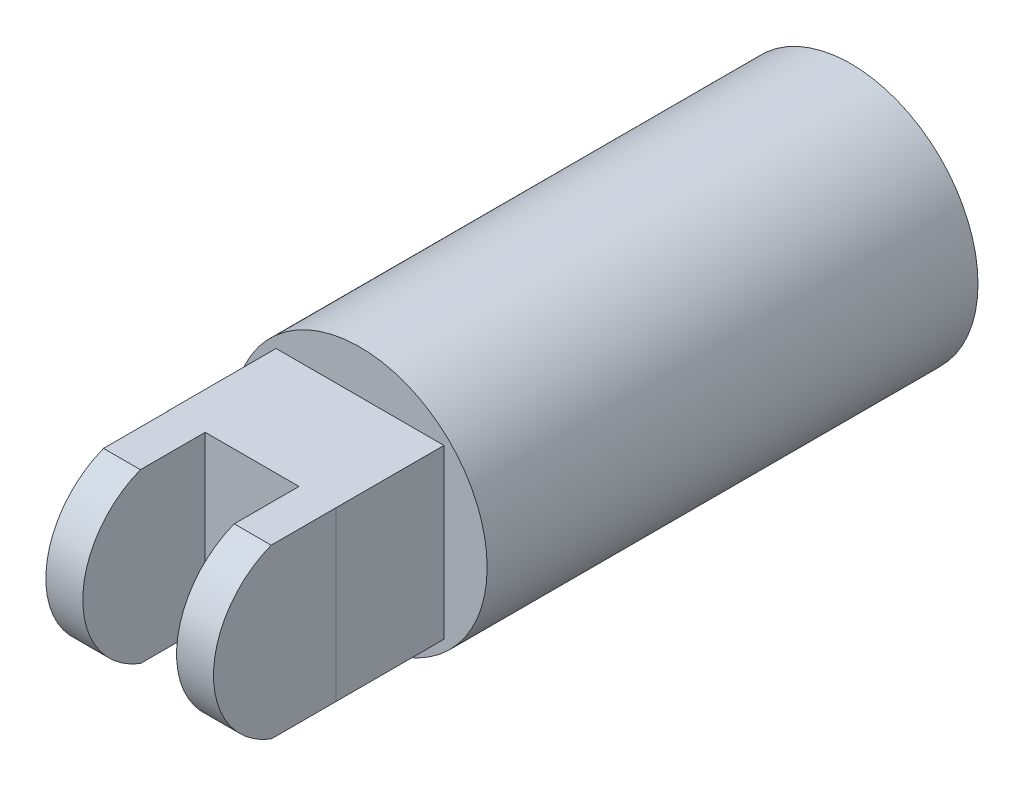
from build123d import *

# Parameters (mm, degrees)
SKETCH1_R           = 6.475
BOSS_EXTRUDE1_DEPTH = 25
SKETCH5_W           = 8.55
SKETCH5_H           = 8.55
BOSS_EXTRUDE2_DEPTH = 5.5
SKETCH10_W          = 1.88
SKETCH10_H          = 8.55
BOSS_EXTRUDE3_DEPTH = 3.3
SKETCH8_W           = 1.88
SKETCH8_H           = 8.55
BOSS_EXTRUDE4_DEPTH = 3.3
BOSS_EXTRUDE5_DEPTH = 1.88
BOSS_EXTRUDE6_DEPTH = 1.88


with BuildPart() as part:
    # Sketch1 → Boss-Extrude1 (new body)
    with BuildSketch(Plane.XY):
        Circle(SKETCH1_R)
    extrude(amount=BOSS_EXTRUDE1_DEPTH)

    # Sketch5 → Boss-Extrude2 (add)
    with BuildSketch(Plane.XY.offset(25)):
        Rectangle(SKETCH5_W, SKETCH5_H)
    extrude(amount=BOSS_EXTRUDE2_DEPTH)

    # Sketch10 → Boss-Extrude3 (add)
    with BuildSketch(Plane.XY.offset(30.5)):
        with Locations((-3.322891498, 0)):
            Rectangle(SKETCH10_W, SKETCH10_H)
    extrude(amount=BOSS_EXTRUDE3_DEPTH)

    # Sketch8 → Boss-Extrude4 (add)
    with BuildSketch(Plane.XY.offset(30.5)):
        with Locations((3.335018839, 0)):
            Rectangle(SKETCH8_W, SKETCH8_H)
    extrude(amount=BOSS_EXTRUDE4_DEPTH)

    # Sketch11 → Boss-Extrude5 (add)
    with BuildSketch(Plane(origin=(4.275018839, 0, 0), x_dir=(0, 0, -1), z_dir=(1, 0, 0))):
        with BuildLine():
            Line((-33.8, 4.275), (-33.8, -4.275))
            ThreePointArc((-33.8, -4.275), (-36.736596519, 0), (-33.8, 4.275))
        make_face()
    extrude(amount=-BOSS_EXTRUDE5_DEPTH)

    # Sketch12 → Boss-Extrude6 (add)
    with BuildSketch(Plane.ZY.offset(4.262891498)):
        with BuildLine():
            Line((33.8, 4.275), (33.8, -4.275))
            ThreePointArc((33.8, -4.275), (36.736596519, 0), (33.8, 4.275))
        make_face()
    extrude(amount=-BOSS_EXTRUDE6_DEPTH)


solid = part.part
